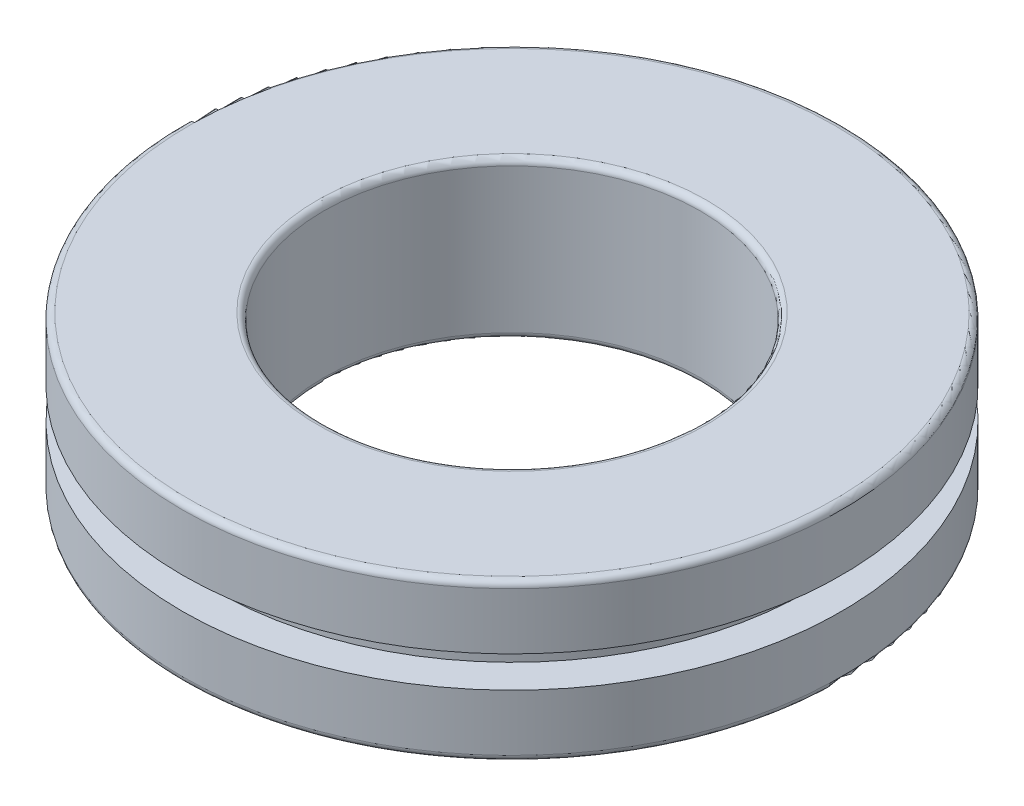
from build123d import *


with BuildPart() as part:
    # Sketch1 → Revolve1 (revolve)
    with BuildSketch(Plane.XY):
        with BuildLine():
            Line((6, 0.2), (6, 4.8))
            ThreePointArc((6, 4.8), (6.058578644, 4.941421356), (6.2, 5))
            Line((6.2, 5), (10.3, 5))
            ThreePointArc((10.3, 5), (10.441421356, 4.941421356), (10.5, 4.8))
            Line((10.5, 4.8), (10.5, 3))
            Line((10.5, 3), (9.411915576, 3))
            Line((9.411915576, 3), (9.411915576, 2))
            Line((9.411915576, 2), (10.5, 2))
            Line((10.5, 2), (10.5, 0.2))
            ThreePointArc((10.5, 0.2), (10.441421356, 0.058578644), (10.3, 0))
            Line((10.3, 0), (6.2, 0))
            ThreePointArc((6.2, 0), (6.058578644, 0.058578644), (6, 0.2))
        make_face()
    revolve(axis=Axis((0, 0, 0), (0, 1, 0)))


solid = part.part
